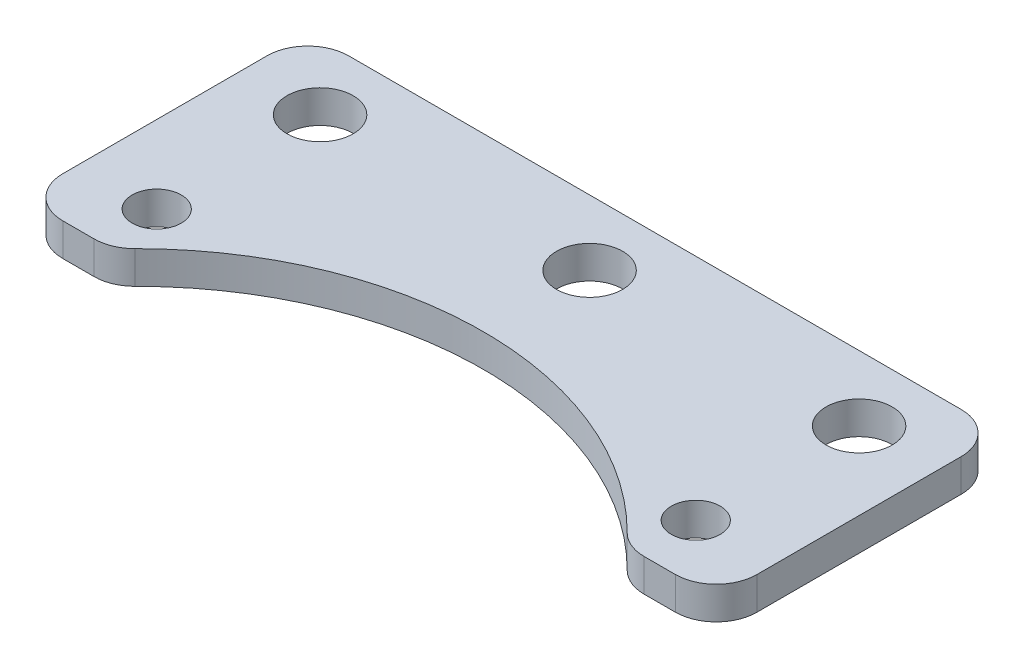
from build123d import *

# Parameters (mm, degrees)
SKETCH1_R           = 3
SKETCH1_R_2         = 4.05
BOSS_EXTRUDE1_DEPTH = 4
FILLET1_R           = 5


with BuildPart() as part:
    # Sketch1 → Boss-Extrude1 (new body)
    with BuildSketch(Plane(origin=(0, 0, 0), x_dir=(1, 0, 0), z_dir=(0, 1, 0))):
        with BuildLine():
            Line((-42.5, 17.5), (-42.5, -17.5))
            Line((-42.5, -17.5), (-31.527765541, -17.5))
            ThreePointArc((-31.527765541, -17.5), (0, -3.5), (31.527765541, -17.5))
            Line((31.527765541, -17.5), (42.5, -17.5))
            Line((42.5, -17.5), (42.5, 17.5))
            Line((42.5, 17.5), (-42.5, 17.5))
        make_face()
        with Locations((-33, -10.5)):
            Circle(SKETCH1_R, mode=Mode.SUBTRACT)
        with Locations((-33, 9.5)):
            Circle(SKETCH1_R_2, mode=Mode.SUBTRACT)
        with Locations((33, -10.5)):
            Circle(SKETCH1_R, mode=Mode.SUBTRACT)
        with Locations((0, 9.5)):
            Circle(SKETCH1_R_2, mode=Mode.SUBTRACT)
        with Locations((33, 9.5)):
            Circle(SKETCH1_R_2, mode=Mode.SUBTRACT)
    extrude(amount=BOSS_EXTRUDE1_DEPTH)

    # Fillet1
    fillet1_edges = [part.edges().sort_by_distance(p)[0] for p in [
        (-31.527765541, 2, 17.5),
        (-42.5, 2, 17.5),
        (-42.5, 2, -17.5),
        (42.5, 2, -17.5),
        (42.5, 2, 17.5),
        (31.527765541, 2, 17.5),
    ]]
    fillet(fillet1_edges, radius=FILLET1_R)


solid = part.part
